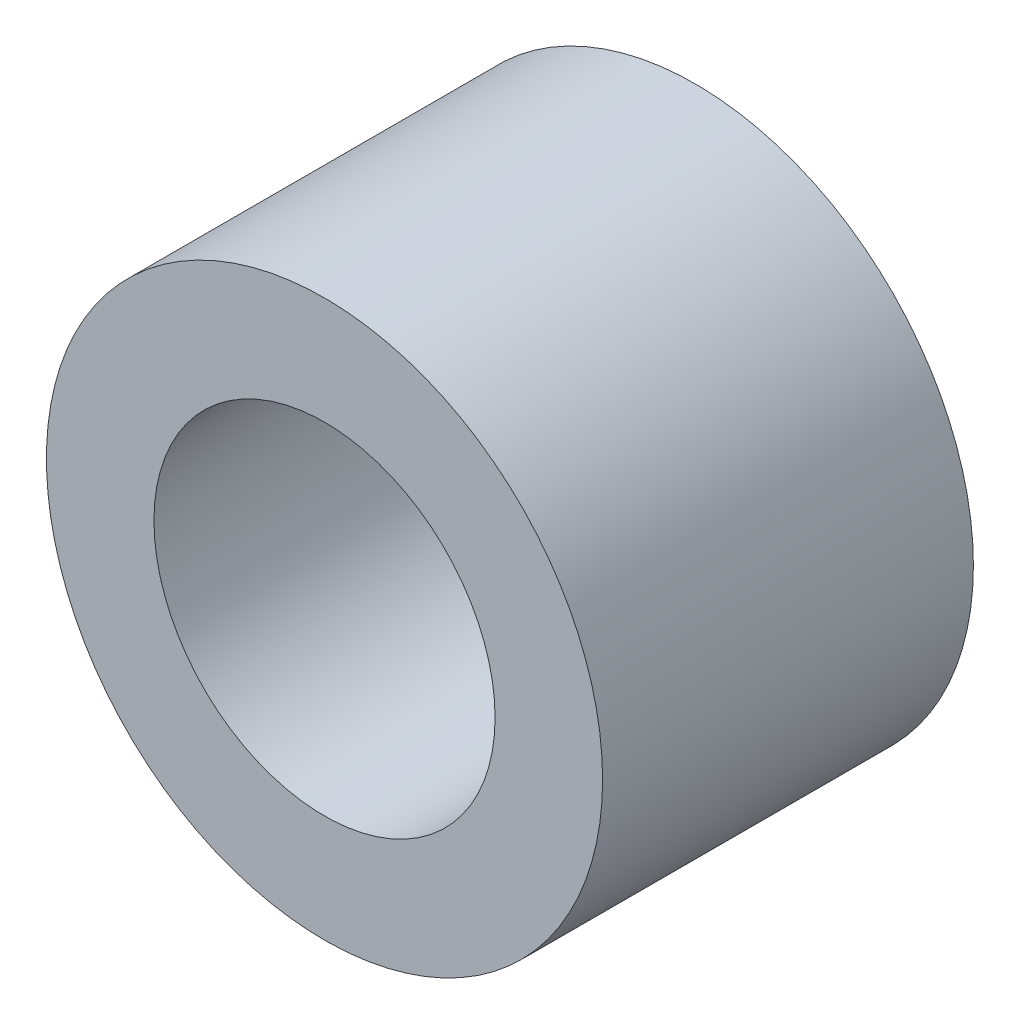
from build123d import *

# Parameters (mm, degrees)
SKETCH1_R           = 2.38125
SKETCH1_R_2         = 1.4605
BOSS_EXTRUDE1_DEPTH = 3.175


with BuildPart() as part:
    # Sketch1 → Boss-Extrude1 (new body)
    with BuildSketch(Plane.XY):
        Circle(SKETCH1_R)
        Circle(SKETCH1_R_2, mode=Mode.SUBTRACT)
    extrude(amount=BOSS_EXTRUDE1_DEPTH)


solid = part.part
